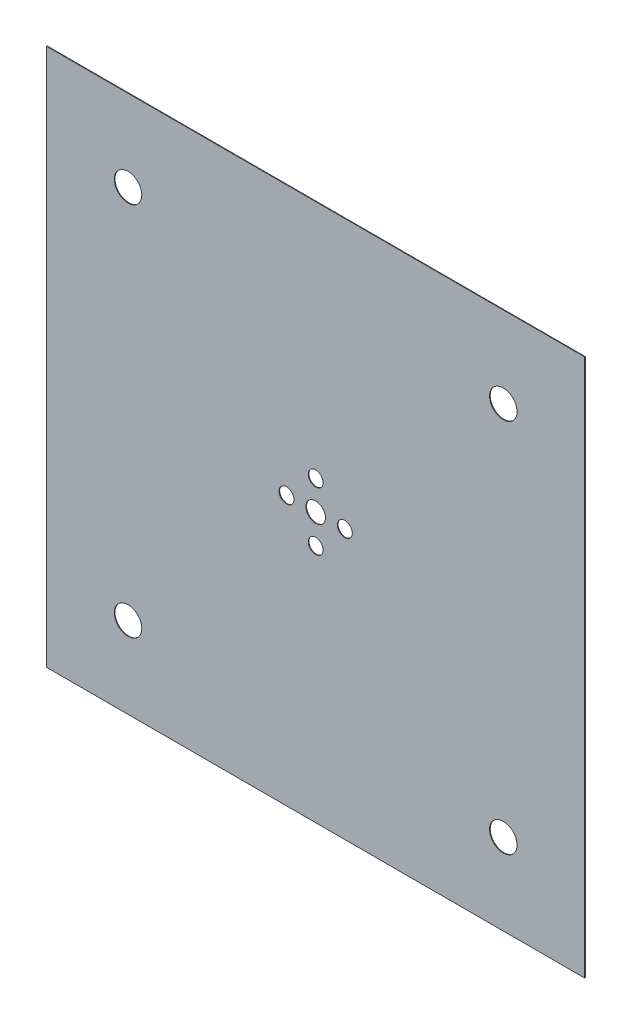
from build123d import *

# Parameters (mm, degrees)
SKETCH1_W           = 2580
SKETCH1_H           = 2580
SKETCH1_R           = 46.75
SKETCH1_R_2         = 35.6375
SKETCH1_R_3         = 65.8
BOSS_EXTRUDE1_DEPTH = 3


with BuildPart() as part:
    # Sketch1 → Boss-Extrude1 (new body)
    with BuildSketch(Plane.XY):
        Rectangle(SKETCH1_W, SKETCH1_H)
        Circle(SKETCH1_R, mode=Mode.SUBTRACT)
        with Locations((0, 140)):
            Circle(SKETCH1_R_2, mode=Mode.SUBTRACT)
        with Locations((-900, 900)):
            Circle(SKETCH1_R_3, mode=Mode.SUBTRACT)
        with Locations((900, 900)):
            Circle(SKETCH1_R_3, mode=Mode.SUBTRACT)
        with Locations((140, 0)):
            Circle(SKETCH1_R_2, mode=Mode.SUBTRACT)
        with Locations((900, -900)):
            Circle(SKETCH1_R_3, mode=Mode.SUBTRACT)
        with Locations((-900, -900)):
            Circle(SKETCH1_R_3, mode=Mode.SUBTRACT)
        with Locations((0, -140)):
            Circle(SKETCH1_R_2, mode=Mode.SUBTRACT)
        with Locations((-140, 0)):
            Circle(SKETCH1_R_2, mode=Mode.SUBTRACT)
    extrude(amount=BOSS_EXTRUDE1_DEPTH)


solid = part.part
